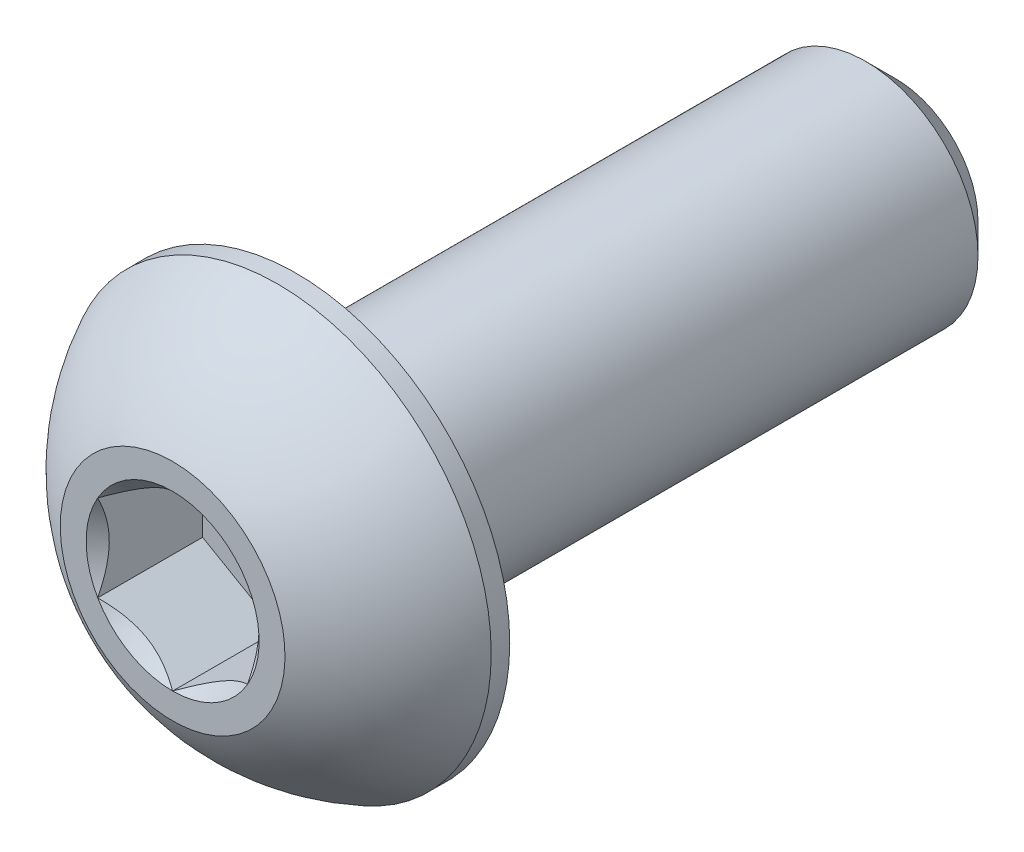
from build123d import *

# Parameters (mm, degrees)
CUT_EXTRUDE1_DEPTH = 1.4


with BuildPart() as part:
    # Sketch2 → Revolve1 (revolve)
    with BuildSketch(Plane(origin=(0, 0, 0), x_dir=(0, 0, -1), z_dir=(1, 0, 0)), mode=Mode.PRIVATE) as revolve1_sk:
        with BuildLine():
            Line((-4.825, 0), (4.825, 0))
            Line((4.825, 0), (4.825, 1.1))
            Line((4.825, 1.1), (4.425, 1.5))
            Line((4.425, 1.5), (-3.175, 1.5))
            Line((-3.175, 1.5), (-3.175, 2.85))
            Line((-3.175, 2.85), (-3.4225, 2.85))
            ThreePointArc((-3.4225, 2.85), (-4.22987489, 2.285251969), (-4.825, 1.5))
            Line((-4.825, 1.5), (-4.825, 0))
        make_face()
    revolve(revolve1_sk.sketch.rotate(Axis((0, 0, 4.825), (0, 0, -1)), 90), axis=Axis((0, 0, 4.825), (0, 0, -1)))

    # Sketch3 → Cut-Extrude1 (cut)
    with BuildSketch(Plane.XY.offset(4.825)):
        Polygon((0, 1.154700538), (-1, 0.577350269), (-1, -0.577350269), (0, -1.154700538), (1, -0.577350269), (1, 0.577350269), align=None)
    extrude(amount=-CUT_EXTRUDE1_DEPTH, mode=Mode.SUBTRACT)

    # Cut-Extrude2 cone 1 section (through the dimple's axis) → Cut-Extrude2 (revolve, cut)
    with BuildSketch(Plane(origin=(0, 0, 4.825), x_dir=(0, -1, 0), z_dir=(1, 0, 0))):
        Polygon((0, 0), (1.154700538, 0), (0, 1.154700538), align=None)
    revolve(axis=Axis((0, 0, 4.825), (0, 0, -1)), mode=Mode.SUBTRACT)


solid = part.part
